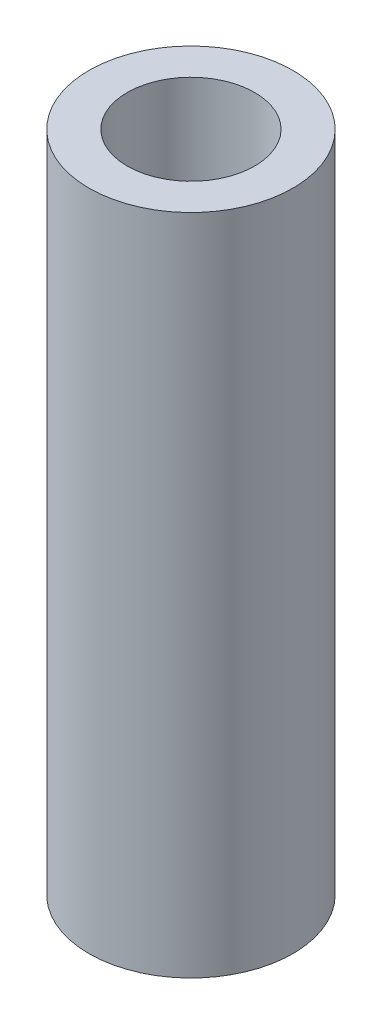
from build123d import *

# Parameters (mm, degrees)
SKETCH1_R           = 4
SKETCH1_R_2         = 2.5
BOSS_EXTRUDE1_DEPTH = 26


with BuildPart() as part:
    # Sketch1 → Boss-Extrude1 (new body)
    with BuildSketch(Plane(origin=(0, 0, 0), x_dir=(1, 0, 0), z_dir=(0, 1, 0))):
        Circle(SKETCH1_R)
        Circle(SKETCH1_R_2, mode=Mode.SUBTRACT)
    extrude(amount=BOSS_EXTRUDE1_DEPTH)


solid = part.part
